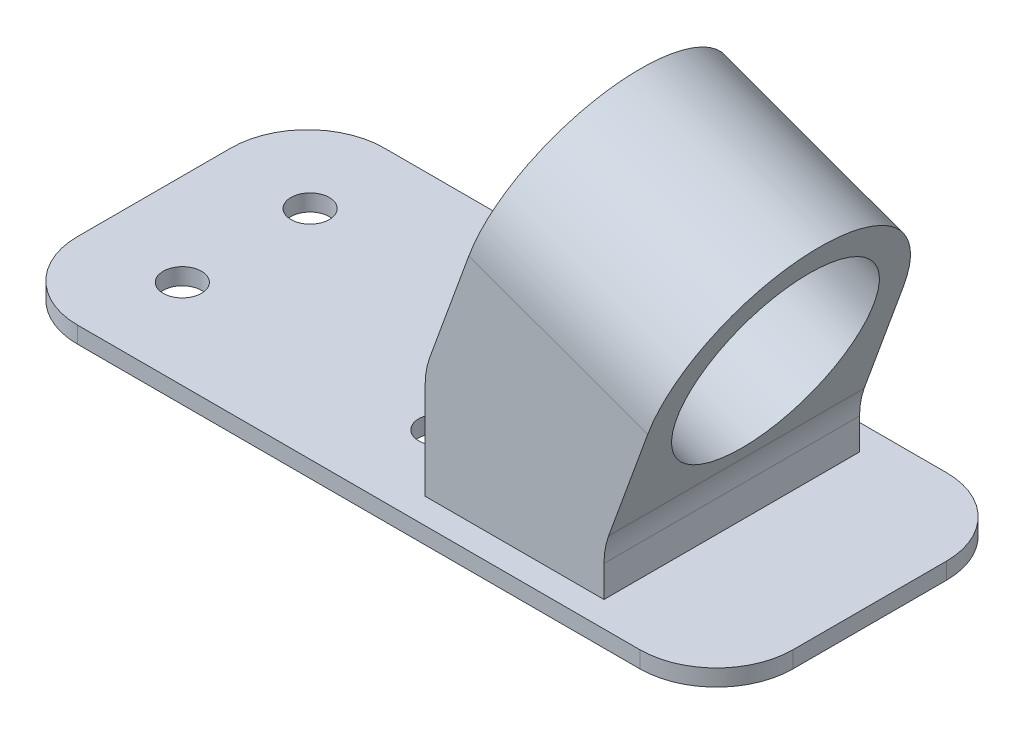
from build123d import *

# Parameters (mm, degrees)
BOSS_EXTRUDE1_DEPTH = 0.65
BOSS_EXTRUDE2_DEPTH = 10
SKETCH9_W           = 7.449244408
SKETCH9_H           = 10
BOSS_EXTRUDE3_DEPTH = 10
CUT_EXTRUDE1_REACH  = 15.344
SKETCH10_R          = 3.85
CUT_EXTRUDE2_REACH  = 2.65
SKETCH6_R           = 0.75
FILLET1_R           = 3


with BuildPart() as part:
    # Sketch1 → Boss-Extrude1 (new body)
    with BuildSketch(Plane(origin=(0, 0, 0), x_dir=(1, 0, 0), z_dir=(0, 1, 0))):
        with BuildLine():
            Line((-11, -6), (11, -6))
            ThreePointArc((11, -6), (13.121320344, -5.121320344), (14, -3))
            Line((14, -3), (14, 3))
            ThreePointArc((14, 3), (13.121320344, 5.121320344), (11, 6))
            Line((11, 6), (-11, 6))
            ThreePointArc((-11, 6), (-13.121320344, 5.121320344), (-14, 3))
            Line((-14, 3), (-14, -3))
            ThreePointArc((-14, -3), (-13.121320344, -5.121320344), (-11, -6))
        make_face()
    extrude(amount=BOSS_EXTRUDE1_DEPTH)

    # Sketch8 → Boss-Extrude2 (add)
    with BuildSketch(Plane.XY.offset(5)):
        Polygon((1.6, 0.65), (1.6, 4.94779164), (8.6, 2.4), (8.6, 0.65), align=None)
    extrude(amount=-BOSS_EXTRUDE2_DEPTH)

    # Sketch9 → Boss-Extrude3 (add)
    with BuildSketch(Plane(origin=(1.777354026, 4.883240053, 0), x_dir=(0.939692621, -0.342020143, 0), z_dir=(0.342020143, 0.939692621, 0))):
        with Locations((3.535885991, 0)):
            Rectangle(SKETCH9_W, SKETCH9_H)
    extrude(amount=BOSS_EXTRUDE3_DEPTH)

    # Sketch10 → Cut-Extrude1 (cut, up to next)
    with BuildSketch(Plane(origin=(-0.177354026, 0.064551586, 0), x_dir=(0, 0, 1), z_dir=(-0.939692621, 0.342020143, 0)), mode=Mode.PRIVATE) as cut_extrude1_sk1:
        with BuildLine():
            Line((5, 15.196635522), (-6.8e-08, 15.196635522))
            ThreePointArc((-6.8e-08, 15.196635522), (3.535533882, 13.732169453), (5, 10.196635522))
            Line((5, 10.196635522), (5, 15.196635522))
        make_face()
    cut_extrude1_tool1 = extrude(cut_extrude1_sk1.sketch, amount=-CUT_EXTRUDE1_REACH, mode=Mode.PRIVATE) & part.part
    add(cut_extrude1_tool1.solids().sort_by_distance((4.63822, 13.295232, 3.88316))[0], mode=Mode.SUBTRACT)
    # Sketch10 → Cut-Extrude1 (cut, up to next)
    with BuildSketch(Plane(origin=(-0.177354026, 0.064551586, 0), x_dir=(0, 0, 1), z_dir=(-0.939692621, 0.342020143, 0)), mode=Mode.PRIVATE) as cut_extrude1_sk2:
        with BuildLine():
            Line((-5, 15.196635522), (-5, 10.196635522))
            ThreePointArc((-5, 10.196635522), (-3.53553393, 13.732169404), (-6.8e-08, 15.196635522))
            Line((-6.8e-08, 15.196635522), (-5, 15.196635522))
        make_face()
    cut_extrude1_tool2 = extrude(cut_extrude1_sk2.sketch, amount=-CUT_EXTRUDE1_REACH, mode=Mode.PRIVATE) & part.part
    add(cut_extrude1_tool2.solids().sort_by_distance((4.63822, 13.295232, -3.88316))[0], mode=Mode.SUBTRACT)
    # Sketch10 → Cut-Extrude1 (cut, up to next)
    with BuildSketch(Plane(origin=(-0.177354026, 0.064551586, 0), x_dir=(0, 0, 1), z_dir=(-0.939692621, 0.342020143, 0)), mode=Mode.PRIVATE) as cut_extrude1_sk3:
        with Locations((0, 10.196635522)):
            Circle(SKETCH10_R)
    cut_extrude1_tool3 = extrude(cut_extrude1_sk3.sketch, amount=-CUT_EXTRUDE1_REACH, mode=Mode.PRIVATE) & part.part
    add(cut_extrude1_tool3.solids().sort_by_distance((3.310101, 9.646255, 0))[0], mode=Mode.SUBTRACT)

    # Sketch6 → Cut-Extrude2 (cut, up to next)
    with BuildSketch(Plane(origin=(0, 0.65, 0), x_dir=(1, 0, 0), z_dir=(0, 1, 0)), mode=Mode.PRIVATE) as cut_extrude2_sk1:
        with Locations((-10.4, 2.5)):
            Circle(SKETCH6_R)
    cut_extrude2_tool1 = extrude(cut_extrude2_sk1.sketch, amount=-CUT_EXTRUDE2_REACH, mode=Mode.PRIVATE) & part.part
    add(cut_extrude2_tool1.solids().sort_by_distance((-10.4, 0.65, -2.5))[0], mode=Mode.SUBTRACT)
    # Sketch6 → Cut-Extrude2 (cut, up to next)
    with BuildSketch(Plane(origin=(0, 0.65, 0), x_dir=(1, 0, 0), z_dir=(0, 1, 0)), mode=Mode.PRIVATE) as cut_extrude2_sk2:
        with Locations((-0.4, 2.5)):
            Circle(SKETCH6_R)
    cut_extrude2_tool2 = extrude(cut_extrude2_sk2.sketch, amount=-CUT_EXTRUDE2_REACH, mode=Mode.PRIVATE) & part.part
    add(cut_extrude2_tool2.solids().sort_by_distance((-0.4, 0.65, -2.5))[0], mode=Mode.SUBTRACT)
    # Sketch6 → Cut-Extrude2 (cut, up to next)
    with BuildSketch(Plane(origin=(0, 0.65, 0), x_dir=(1, 0, 0), z_dir=(0, 1, 0)), mode=Mode.PRIVATE) as cut_extrude2_sk3:
        with Locations((-0.4, -2.5)):
            Circle(SKETCH6_R)
    cut_extrude2_tool3 = extrude(cut_extrude2_sk3.sketch, amount=-CUT_EXTRUDE2_REACH, mode=Mode.PRIVATE) & part.part
    add(cut_extrude2_tool3.solids().sort_by_distance((-0.4, 0.65, 2.5))[0], mode=Mode.SUBTRACT)
    # Sketch6 → Cut-Extrude2 (cut, up to next)
    with BuildSketch(Plane(origin=(0, 0.65, 0), x_dir=(1, 0, 0), z_dir=(0, 1, 0)), mode=Mode.PRIVATE) as cut_extrude2_sk4:
        with Locations((-10.4, -2.5)):
            Circle(SKETCH6_R)
    cut_extrude2_tool4 = extrude(cut_extrude2_sk4.sketch, amount=-CUT_EXTRUDE2_REACH, mode=Mode.PRIVATE) & part.part
    add(cut_extrude2_tool4.solids().sort_by_distance((-10.4, 0.65, 2.5))[0], mode=Mode.SUBTRACT)

    # Fillet1
    fillet1_edges = [part.edges().sort_by_distance(p)[0] for p in [
        (1.6, 4.94779164, 0),
        (8.6, 2.4, 0),
    ]]
    fillet(fillet1_edges, radius=FILLET1_R)


solid = part.part
